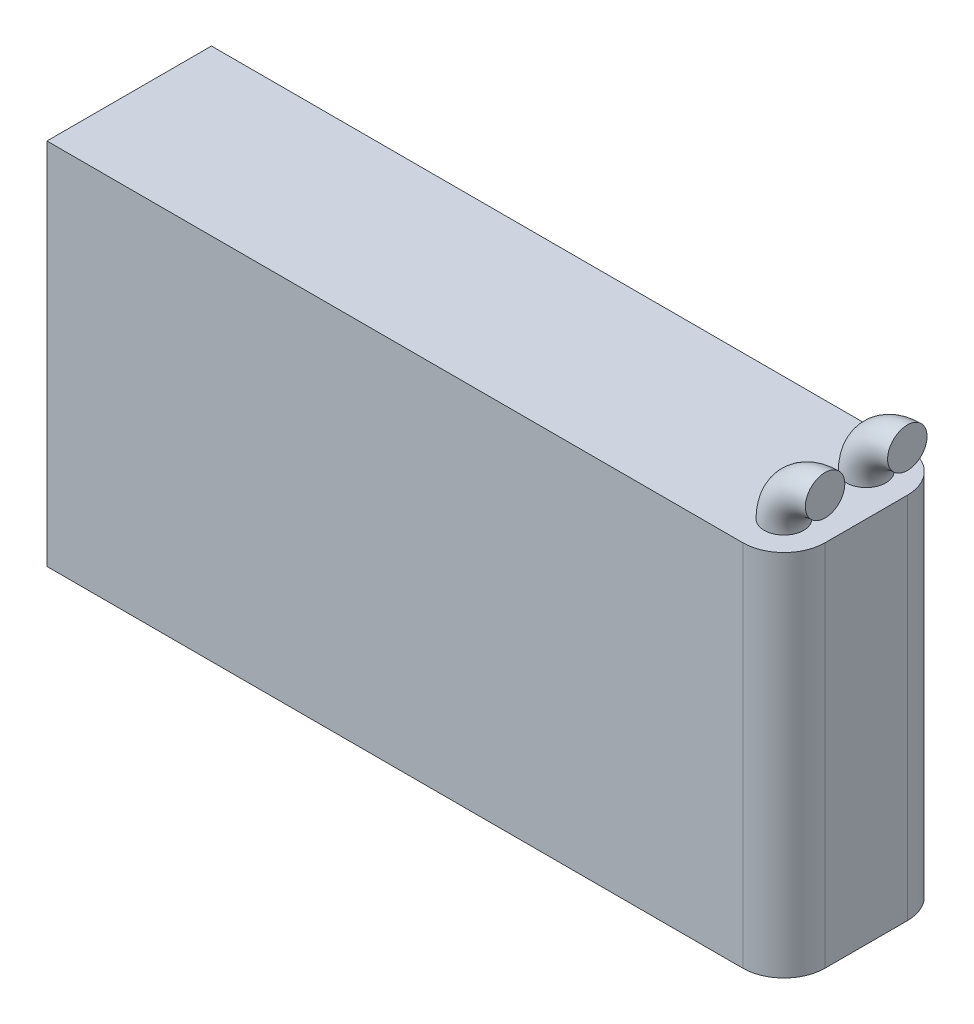
from build123d import *

# Parameters (mm, degrees)
SKETCH2_W           = 71.12
SKETCH2_H           = 15.875
BOSS_EXTRUDE1_DEPTH = 35.56
FILLET1_R           = 3.96875
SKETCH3_R           = 1.905
REVOLVE1_ANGLE      = 90


with BuildPart() as part:
    # Sketch2 → Boss-Extrude1 (new body)
    with BuildSketch(Plane(origin=(0, 0, 0), x_dir=(1, 0, 0), z_dir=(0, 1, 0))):
        Rectangle(SKETCH2_W, SKETCH2_H)
    extrude(amount=BOSS_EXTRUDE1_DEPTH)

    # Fillet1
    fillet1_edges = [part.edges().sort_by_distance(p)[0] for p in [
        (35.56, 17.78, 7.9375),
        (35.56, 17.78, -7.9375),
    ]]
    fillet(fillet1_edges, radius=FILLET1_R)

    # Sketch3 → Revolve1 (revolve)
    with BuildSketch(Plane(origin=(0, 35.56, 0), x_dir=(1, 0, 0), z_dir=(0, 1, 0))):
        with Locations((31.59125, -3.96875)):
            Circle(SKETCH3_R)
        with Locations((31.59125, 3.96875)):
            Circle(SKETCH3_R)
    revolve(axis=Axis((35.56, 35.56, -7.9375), (0, 0, -1)), revolution_arc=REVOLVE1_ANGLE)


solid = part.part
